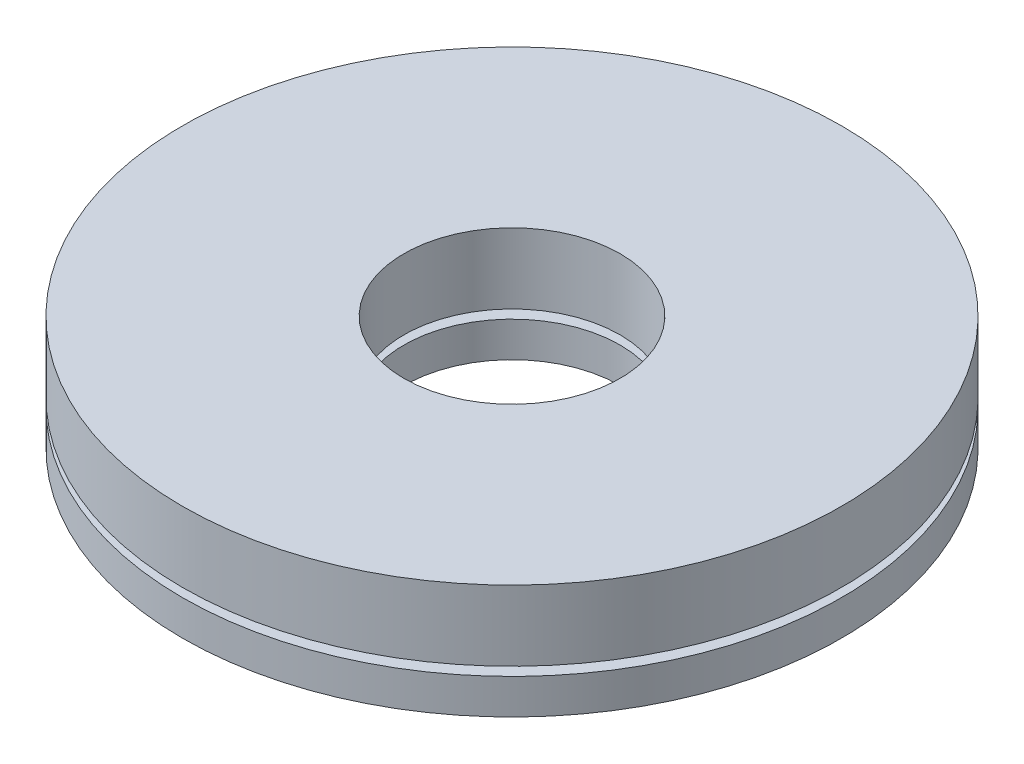
from build123d import *

# Parameters (mm, degrees)
SKETCH1_R           = 9.375
SKETCH1_R_2         = 3.075
BOSS_EXTRUDE1_DEPTH = 1
SKETCH2_R           = 9.375
SKETCH2_R_2         = 3.075
BOSS_EXTRUDE2_DEPTH = 1


with BuildPart() as part:
    # Sketch1 → Boss-Extrude1 (new body, symmetric)
    with BuildSketch(Plane(origin=(0, 0, 0), x_dir=(1, 0, 0), z_dir=(0, 1, 0))):
        Circle(SKETCH1_R)
        Circle(SKETCH1_R_2, mode=Mode.SUBTRACT)
    extrude(amount=BOSS_EXTRUDE1_DEPTH, both=True)


with BuildPart() as body_2:
    # Sketch2 → Boss-Extrude2 (new body)
    with BuildSketch(Plane(origin=(0, -1.25, 0), x_dir=(-1, 0, 0), z_dir=(0, -1, 0))):
        Circle(SKETCH2_R)
        Circle(SKETCH2_R_2, mode=Mode.SUBTRACT)
    extrude(amount=BOSS_EXTRUDE2_DEPTH)


solid = Compound([part.part, body_2.part])
